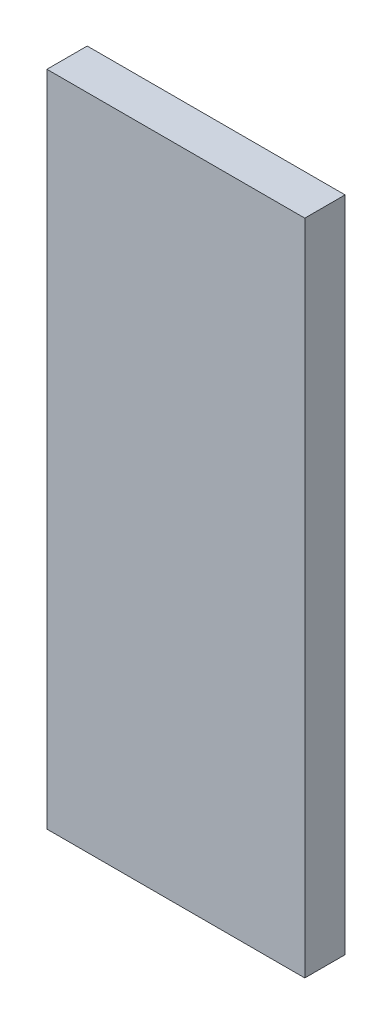
from build123d import *

# Parameters (mm, degrees)
SKETCH1_W           = 96
SKETCH1_H           = 15
BOSS_EXTRUDE1_DEPTH = 245


with BuildPart() as part:
    # Sketch1 → Boss-Extrude1 (new body)
    with BuildSketch(Plane(origin=(0, 0, 0), x_dir=(1, 0, 0), z_dir=(0, 1, 0))):
        Rectangle(SKETCH1_W, SKETCH1_H)
    extrude(amount=BOSS_EXTRUDE1_DEPTH)


solid = part.part
